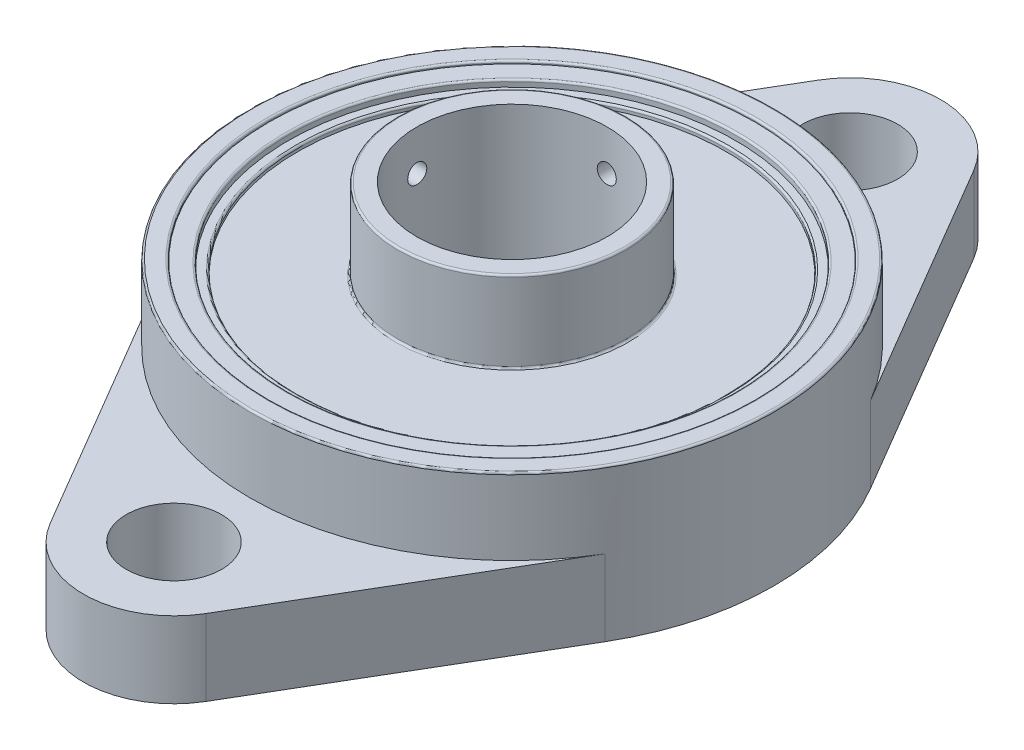
from build123d import *

# Parameters (mm, degrees)
SKETCH1_R             = 5
SKETCH1_R_2           = 27.5
SKETCH1_R_3           = 25.5
EXTRUDE_A1_DEPTH      = 8
SKETCH1_3_R           = 27.5
SKETCH1_3_R_2         = 25.5
EXTRUDE_A_DEPTH       = 16
SKETCH1_4_R           = 12
SKETCH1_4_R_2         = 10
EXTRUDE_A0_DEPTH      = 23
BEARING_START         = 2
SKETCH1_7_R           = 23.5
SKETCH1_7_R_2         = 22.5
BEARING_OUTER_D_DEPTH = 13
BOSS_EXTRUDE6_START   = 1.2
SKETCH1_8_R           = 25.5
SKETCH1_8_R_2         = 23.5
BOSS_EXTRUDE6_DEPTH   = 14.5
BOSS_EXTRUDE7_START   = 1.5
SKETCH1_9_R           = 22.5
SKETCH1_9_R_2         = 12
BOSS_EXTRUDE7_DEPTH   = 13
CUT_EXTRUDE1_REACH    = 29.5
SKETCH2_R             = 1
CUT_EXTRUDE2_REACH    = 47
SKETCH3_R             = 1
FILLET1_R             = 0.2
FILLET2_R             = 0.2


with BuildPart() as part:
    # Sketch1 → Extrude A1 (new body)
    with BuildSketch(Plane(origin=(0, 0, 0), x_dir=(1, 0, 0), z_dir=(0, 1, 0))):
        with BuildLine():
            Line((8.18825139, -40.316901408), (23.70283297, -13.943661972))
            ThreePointArc((23.70283297, -13.943661972), (0, -27.5), (-23.70283297, -13.943661972))
            Line((-23.70283297, -13.943661972), (-8.18825139, -40.316901408))
            ThreePointArc((-8.18825139, -40.316901408), (0, -45), (8.18825139, -40.316901408))
        make_face()
        with Locations((0, -35.5)):
            Circle(SKETCH1_R, mode=Mode.SUBTRACT)
        Circle(SKETCH1_R_2)
        Circle(SKETCH1_R_3, mode=Mode.SUBTRACT)
        with BuildLine():
            Line((-8.18825139, 40.316901408), (-23.70283297, 13.943661972))
            ThreePointArc((-23.70283297, 13.943661972), (0, 27.5), (23.70283297, 13.943661972))
            Line((23.70283297, 13.943661972), (8.18825139, 40.316901408))
            ThreePointArc((8.18825139, 40.316901408), (0, 45), (-8.18825139, 40.316901408))
        make_face()
        with Locations((0, 35.5)):
            Circle(SKETCH1_R, mode=Mode.SUBTRACT)
    extrude(amount=EXTRUDE_A1_DEPTH)

    # Sketch1_3 → Extrude A (add)
    with BuildSketch(Plane(origin=(0, 0, 0), x_dir=(1, 0, 0), z_dir=(0, 1, 0))):
        Circle(SKETCH1_3_R)
        Circle(SKETCH1_3_R_2, mode=Mode.SUBTRACT)
    extrude(amount=EXTRUDE_A_DEPTH)



with BuildPart() as body_2:
    # Sketch1_4 → Extrude A0 (new body)
    with BuildSketch(Plane(origin=(0, 0, 0), x_dir=(1, 0, 0), z_dir=(0, 1, 0))):
        Circle(SKETCH1_4_R)
        Circle(SKETCH1_4_R_2, mode=Mode.SUBTRACT)
    extrude(amount=EXTRUDE_A0_DEPTH)


with BuildPart() as body_3:
    # Sketch1_7 → Bearing outer d (new body)
    with BuildSketch(Plane(origin=(0, 0, 0), x_dir=(1, 0, 0), z_dir=(0, 1, 0)).offset(BEARING_START)):
        Circle(SKETCH1_7_R)
        Circle(SKETCH1_7_R_2, mode=Mode.SUBTRACT)
    extrude(amount=BEARING_OUTER_D_DEPTH)


with BuildPart() as part_1:
    add(part.part)

    add(body_3.part)  # Boss-Extrude6 merges body 3
    # Sketch1_8 → Boss-Extrude6 (add)
    with BuildSketch(Plane(origin=(0, 0, 0), x_dir=(1, 0, 0), z_dir=(0, 1, 0)).offset(BOSS_EXTRUDE6_START)):
        Circle(SKETCH1_8_R)
        Circle(SKETCH1_8_R_2, mode=Mode.SUBTRACT)
    extrude(amount=BOSS_EXTRUDE6_DEPTH)


    add(body_2.part)  # Boss-Extrude7 merges body 2
    # Sketch1_9 → Boss-Extrude7 (add)
    with BuildSketch(Plane(origin=(0, 0, 0), x_dir=(1, 0, 0), z_dir=(0, 1, 0)).offset(BOSS_EXTRUDE7_START)):
        Circle(SKETCH1_9_R)
        Circle(SKETCH1_9_R_2, mode=Mode.SUBTRACT)
    extrude(amount=BOSS_EXTRUDE7_DEPTH)

    # Sketch2 → Cut-Extrude1 (cut, up to next)
    with BuildSketch(Plane(origin=(0, 0, 0), x_dir=(0, 0, -1), z_dir=(1, 0, 0)), mode=Mode.PRIVATE) as cut_extrude1_sk1:
        with Locations((0, 18.75)):
            Circle(SKETCH2_R)
    cut_extrude1_tool1 = extrude(cut_extrude1_sk1.sketch, amount=-CUT_EXTRUDE1_REACH, mode=Mode.PRIVATE) & part_1.part
    add(cut_extrude1_tool1.solids().sort_by_distance((0, 18.75, 0))[0], mode=Mode.SUBTRACT)

    # Sketch3 → Cut-Extrude2 (cut, up to next)
    with BuildSketch(Plane.XY, mode=Mode.PRIVATE) as cut_extrude2_sk1:
        with Locations((0, 18.75)):
            Circle(SKETCH3_R)
    cut_extrude2_tool1 = extrude(cut_extrude2_sk1.sketch, amount=-CUT_EXTRUDE2_REACH, mode=Mode.PRIVATE) & part_1.part
    add(cut_extrude2_tool1.solids().sort_by_distance((0, 18.75, 0))[0], mode=Mode.SUBTRACT)

    # Fillet1
    fillet1_edges = [part_1.edges().sort_by_distance(p)[0] for p in [
        (-22.5, 15, 0),
    ]]
    fillet(fillet1_edges, radius=FILLET1_R)

    # Fillet2
    fillet2_edges = [part_1.edges().sort_by_distance(p)[0] for p in [
        (-12, 23, 0),
        (-25.5, 16, 0),
        (-27.5, 16, 0),
        (-23.5, 15.7, 0),
        (-12, 14.5, 0),
    ]]
    fillet(fillet2_edges, radius=FILLET2_R)


solid = part_1.part
